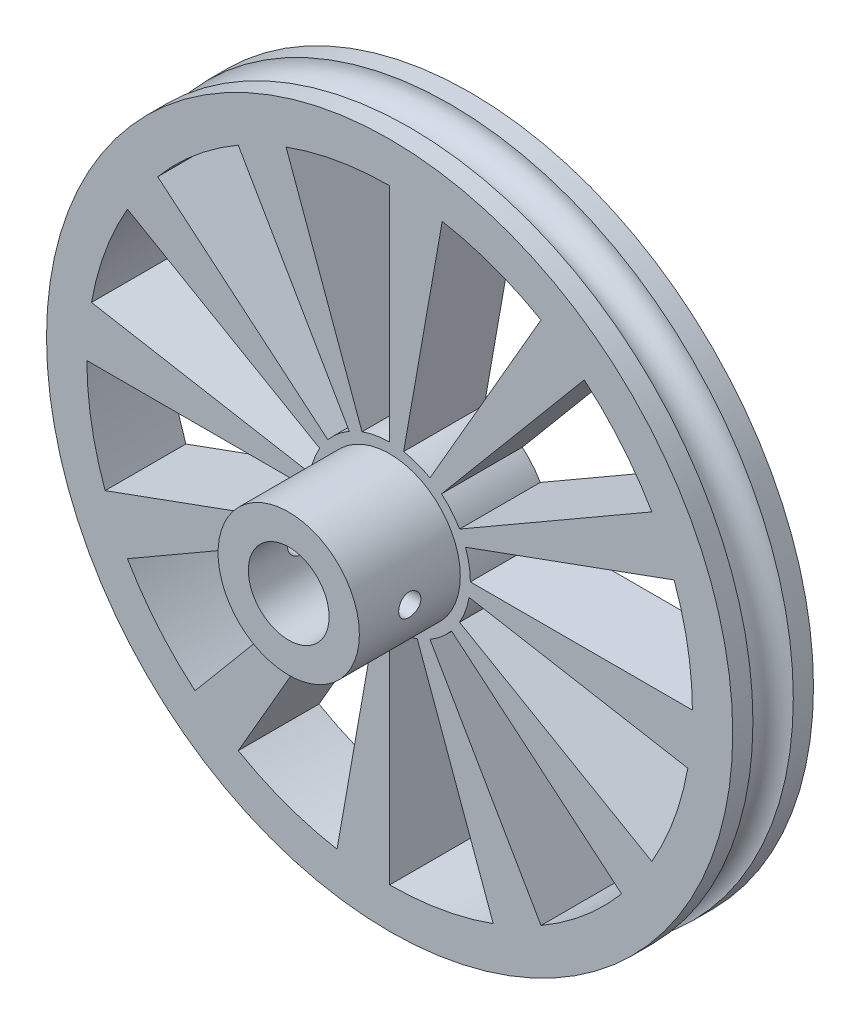
from build123d import *

# Parameters (mm, degrees)
CUT_EXTRUDE_1_REACH             = 10
CUT_EXTRUDE_2_REACH             = 36
SKETCH_4_R                      = 1.1
CUT_EXTRUDE_2_DIRECTION_2_REACH = 36


with BuildPart() as part:
    # 草图2 → 旋转1 (revolve)
    with BuildSketch(Plane(origin=(0, 0, 0), x_dir=(1, 0, 0), z_dir=(0, 1, 0))):
        with BuildLine():
            Line((-4, -4), (-4, 4))
            Line((-4, 4), (-34, 4))
            Line((-34, 4), (-34, 2))
            ThreePointArc((-34, 2), (-32, 0), (-34, -2))
            Line((-34, -2), (-34, -4))
            Line((-34, -4), (-7, -4))
            Line((-7, -4), (-7, -14))
            Line((-7, -14), (-4, -14))
            Line((-4, -14), (-4, -4))
        make_face()
    revolve(axis=Axis((0, 0, 0), (0, 0, -1)))

    # 草图3 → 切除-拉伸1 (cut, up to next)
    with BuildSketch(Plane.XY.offset(4), mode=Mode.PRIVATE) as cut_extrude_1_sk1:
        with BuildLine():
            Line((-30, 0), (-8, 0))
            ThreePointArc((-8, 0), (-7.878462024, -1.389185421), (-7.517540966, -2.736161147))
            Line((-7.517540966, -2.736161147), (-28.190778624, -10.2606043))
            ThreePointArc((-28.190778624, -10.2606043), (-29.54423259, -5.20944533), (-30, 0))
        make_face()
    cut_extrude_1_tool1 = extrude(cut_extrude_1_sk1.sketch, amount=-CUT_EXTRUDE_1_REACH, mode=Mode.PRIVATE) & part.part
    add(cut_extrude_1_tool1.solids().sort_by_distance((-20.696454, -3.649343, 4))[0], mode=Mode.SUBTRACT)
    # 草图3 → 切除-拉伸1 (cut, up to next)
    with BuildSketch(Plane.XY.offset(4), mode=Mode.PRIVATE) as cut_extrude_1_sk2:
        with BuildLine():
            Line((-29.54423259, 5.20944533), (-7.878462024, 1.389185421))
            ThreePointArc((-7.878462024, 1.389185421), (-7.517540966, 2.736161147), (-6.92820323, 4))
            Line((-6.92820323, 4), (-25.980762114, 15))
            ThreePointArc((-25.980762114, 15), (-28.190778624, 10.2606043), (-29.54423259, 5.20944533))
        make_face()
    cut_extrude_1_tool2 = extrude(cut_extrude_1_sk2.sketch, amount=-CUT_EXTRUDE_1_REACH, mode=Mode.PRIVATE) & part.part
    add(cut_extrude_1_tool2.solids().sort_by_distance((-19.748327, 7.187803, 4))[0], mode=Mode.SUBTRACT)
    # 草图3 → 切除-拉伸1 (cut, up to next)
    with BuildSketch(Plane.XY.offset(4), mode=Mode.PRIVATE) as cut_extrude_1_sk3:
        with BuildLine():
            Line((-22.981333294, 19.283628291), (-6.128355545, 5.142300877))
            ThreePointArc((-6.128355545, 5.142300877), (-5.142300877, 6.128355545), (-4, 6.92820323))
            Line((-4, 6.92820323), (-15, 25.980762114))
            ThreePointArc((-15, 25.980762114), (-19.283628291, 22.981333294), (-22.981333294, 19.283628291))
        make_face()
    cut_extrude_1_tool3 = extrude(cut_extrude_1_sk3.sketch, amount=-CUT_EXTRUDE_1_REACH, mode=Mode.PRIVATE) & part.part
    add(cut_extrude_1_tool3.solids().sort_by_distance((-13.508651, 16.098984, 4))[0], mode=Mode.SUBTRACT)
    # 草图3 → 切除-拉伸1 (cut, up to next)
    with BuildSketch(Plane.XY.offset(4), mode=Mode.PRIVATE) as cut_extrude_1_sk4:
        with BuildLine():
            Line((-10.2606043, 28.190778624), (-2.736161147, 7.517540966))
            ThreePointArc((-2.736161147, 7.517540966), (-1.389185421, 7.878462024), (0, 8))
            Line((0, 8), (0, 30))
            ThreePointArc((0, 30), (-5.20944533, 29.54423259), (-10.2606043, 28.190778624))
        make_face()
    cut_extrude_1_tool4 = extrude(cut_extrude_1_sk4.sketch, amount=-CUT_EXTRUDE_1_REACH, mode=Mode.PRIVATE) & part.part
    add(cut_extrude_1_tool4.solids().sort_by_distance((-3.649343, 20.696454, 4))[0], mode=Mode.SUBTRACT)
    # 草图3 → 切除-拉伸1 (cut, up to next)
    with BuildSketch(Plane.XY.offset(4), mode=Mode.PRIVATE) as cut_extrude_1_sk5:
        with BuildLine():
            Line((5.20944533, 29.54423259), (1.389185421, 7.878462024))
            ThreePointArc((1.389185421, 7.878462024), (2.736161147, 7.517540966), (4, 6.92820323))
            Line((4, 6.92820323), (15, 25.980762114))
            ThreePointArc((15, 25.980762114), (10.2606043, 28.190778624), (5.20944533, 29.54423259))
        make_face()
    cut_extrude_1_tool5 = extrude(cut_extrude_1_sk5.sketch, amount=-CUT_EXTRUDE_1_REACH, mode=Mode.PRIVATE) & part.part
    add(cut_extrude_1_tool5.solids().sort_by_distance((7.187803, 19.748327, 4))[0], mode=Mode.SUBTRACT)
    # 草图3 → 切除-拉伸1 (cut, up to next)
    with BuildSketch(Plane.XY.offset(4), mode=Mode.PRIVATE) as cut_extrude_1_sk6:
        with BuildLine():
            Line((19.283628291, 22.981333294), (5.142300877, 6.128355545))
            ThreePointArc((5.142300877, 6.128355545), (6.128355545, 5.142300877), (6.92820323, 4))
            Line((6.92820323, 4), (25.980762114, 15))
            ThreePointArc((25.980762114, 15), (22.981333294, 19.283628291), (19.283628291, 22.981333294))
        make_face()
    cut_extrude_1_tool6 = extrude(cut_extrude_1_sk6.sketch, amount=-CUT_EXTRUDE_1_REACH, mode=Mode.PRIVATE) & part.part
    add(cut_extrude_1_tool6.solids().sort_by_distance((16.098984, 13.508651, 4))[0], mode=Mode.SUBTRACT)
    # 草图3 → 切除-拉伸1 (cut, up to next)
    with BuildSketch(Plane.XY.offset(4), mode=Mode.PRIVATE) as cut_extrude_1_sk7:
        with BuildLine():
            Line((28.190778624, 10.2606043), (7.517540966, 2.736161147))
            ThreePointArc((7.517540966, 2.736161147), (7.878462024, 1.389185421), (8, 0))
            Line((8, 0), (30, 0))
            ThreePointArc((30, 0), (29.54423259, 5.20944533), (28.190778624, 10.2606043))
        make_face()
    cut_extrude_1_tool7 = extrude(cut_extrude_1_sk7.sketch, amount=-CUT_EXTRUDE_1_REACH, mode=Mode.PRIVATE) & part.part
    add(cut_extrude_1_tool7.solids().sort_by_distance((20.696454, 3.649343, 4))[0], mode=Mode.SUBTRACT)
    # 草图3 → 切除-拉伸1 (cut, up to next)
    with BuildSketch(Plane.XY.offset(4), mode=Mode.PRIVATE) as cut_extrude_1_sk8:
        with BuildLine():
            Line((29.54423259, -5.20944533), (7.878462024, -1.389185421))
            ThreePointArc((7.878462024, -1.389185421), (7.517540966, -2.736161147), (6.92820323, -4))
            Line((6.92820323, -4), (25.980762114, -15))
            ThreePointArc((25.980762114, -15), (28.190778624, -10.2606043), (29.54423259, -5.20944533))
        make_face()
    cut_extrude_1_tool8 = extrude(cut_extrude_1_sk8.sketch, amount=-CUT_EXTRUDE_1_REACH, mode=Mode.PRIVATE) & part.part
    add(cut_extrude_1_tool8.solids().sort_by_distance((19.748327, -7.187803, 4))[0], mode=Mode.SUBTRACT)
    # 草图3 → 切除-拉伸1 (cut, up to next)
    with BuildSketch(Plane.XY.offset(4), mode=Mode.PRIVATE) as cut_extrude_1_sk9:
        with BuildLine():
            Line((22.981333294, -19.283628291), (6.128355545, -5.142300877))
            ThreePointArc((6.128355545, -5.142300877), (5.142300877, -6.128355545), (4, -6.92820323))
            Line((4, -6.92820323), (15, -25.980762114))
            ThreePointArc((15, -25.980762114), (19.283628291, -22.981333294), (22.981333294, -19.283628291))
        make_face()
    cut_extrude_1_tool9 = extrude(cut_extrude_1_sk9.sketch, amount=-CUT_EXTRUDE_1_REACH, mode=Mode.PRIVATE) & part.part
    add(cut_extrude_1_tool9.solids().sort_by_distance((13.508651, -16.098984, 4))[0], mode=Mode.SUBTRACT)
    # 草图3 → 切除-拉伸1 (cut, up to next)
    with BuildSketch(Plane.XY.offset(4), mode=Mode.PRIVATE) as cut_extrude_1_sk10:
        with BuildLine():
            Line((10.2606043, -28.190778624), (2.736161147, -7.517540966))
            ThreePointArc((2.736161147, -7.517540966), (1.389185421, -7.878462024), (0, -8))
            Line((0, -8), (0, -30))
            ThreePointArc((0, -30), (5.20944533, -29.54423259), (10.2606043, -28.190778624))
        make_face()
    cut_extrude_1_tool10 = extrude(cut_extrude_1_sk10.sketch, amount=-CUT_EXTRUDE_1_REACH, mode=Mode.PRIVATE) & part.part
    add(cut_extrude_1_tool10.solids().sort_by_distance((3.649343, -20.696454, 4))[0], mode=Mode.SUBTRACT)
    # 草图3 → 切除-拉伸1 (cut, up to next)
    with BuildSketch(Plane.XY.offset(4), mode=Mode.PRIVATE) as cut_extrude_1_sk11:
        with BuildLine():
            Line((-5.20944533, -29.54423259), (-1.389185421, -7.878462024))
            ThreePointArc((-1.389185421, -7.878462024), (-2.736161147, -7.517540966), (-4, -6.92820323))
            Line((-4, -6.92820323), (-15, -25.980762114))
            ThreePointArc((-15, -25.980762114), (-10.2606043, -28.190778624), (-5.20944533, -29.54423259))
        make_face()
    cut_extrude_1_tool11 = extrude(cut_extrude_1_sk11.sketch, amount=-CUT_EXTRUDE_1_REACH, mode=Mode.PRIVATE) & part.part
    add(cut_extrude_1_tool11.solids().sort_by_distance((-7.187803, -19.748327, 4))[0], mode=Mode.SUBTRACT)
    # 草图3 → 切除-拉伸1 (cut, up to next)
    with BuildSketch(Plane.XY.offset(4), mode=Mode.PRIVATE) as cut_extrude_1_sk12:
        with BuildLine():
            Line((-19.283628291, -22.981333294), (-5.142300877, -6.128355545))
            ThreePointArc((-5.142300877, -6.128355545), (-6.128355545, -5.142300877), (-6.92820323, -4))
            Line((-6.92820323, -4), (-25.980762114, -15))
            ThreePointArc((-25.980762114, -15), (-22.981333294, -19.283628291), (-19.283628291, -22.981333294))
        make_face()
    cut_extrude_1_tool12 = extrude(cut_extrude_1_sk12.sketch, amount=-CUT_EXTRUDE_1_REACH, mode=Mode.PRIVATE) & part.part
    add(cut_extrude_1_tool12.solids().sort_by_distance((-16.098984, -13.508651, 4))[0], mode=Mode.SUBTRACT)

    # 草图4 → 切除-拉伸2 (cut, up to next)
    with BuildSketch(Plane(origin=(0, 0, 0), x_dir=(0, 0, -1), z_dir=(1, 0, 0)), mode=Mode.PRIVATE) as cut_extrude_2_sk1:
        with Locations((-9, 0)):
            Circle(SKETCH_4_R)
    cut_extrude_2_tool1 = extrude(cut_extrude_2_sk1.sketch, amount=-CUT_EXTRUDE_2_REACH, mode=Mode.PRIVATE) & part.part
    add(cut_extrude_2_tool1.solids().sort_by_distance((0, 0, 9))[0], mode=Mode.SUBTRACT)

    # 草图4 → 切除-拉伸2 direction 2 (cut, up to next)
    with BuildSketch(Plane(origin=(0, 0, 0), x_dir=(0, 0, -1), z_dir=(1, 0, 0)), mode=Mode.PRIVATE) as cut_extrude_2_direction_2_sk1:
        with Locations((-9, 0)):
            Circle(SKETCH_4_R)
    cut_extrude_2_direction_2_tool1 = extrude(cut_extrude_2_direction_2_sk1.sketch, amount=CUT_EXTRUDE_2_DIRECTION_2_REACH, mode=Mode.PRIVATE) & part.part
    add(cut_extrude_2_direction_2_tool1.solids().sort_by_distance((0, 0, 9))[0], mode=Mode.SUBTRACT)


solid = part.part
